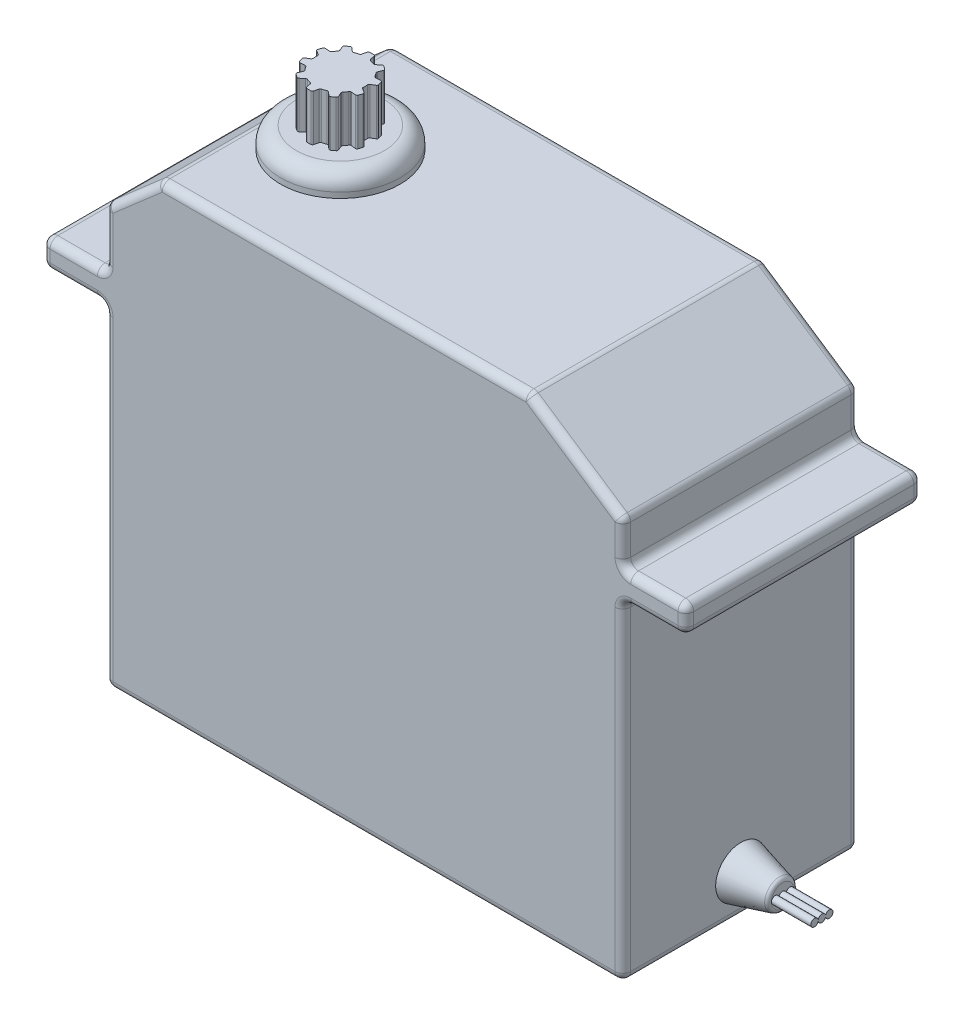
from build123d import *

# Parameters (mm, degrees)
BOSS_EXTRU_1_DEPTH         = 15
BOSS_EXTRU_1_DEPTH_BACK    = 15
ESQUISSE4_R                = 5
ESQUISSE4_R_2              = 4
ENL_V_MAT_EXTRU_1_DEPTH    = 5.9
CONG_2_R                   = 1
CONG_3_R                   = 2
CONG_4_R                   = 0.5
ESQUISSE6_W                = 7.5
ESQUISSE6_H                = 0.471666667
R_P_TITION_LIN_AIRE1_COUNT = 3
R_P_TITION_LIN_AIRE1_PITCH = 0.94


with BuildPart() as part:
    # Esquisse1 → Boss.-Extru.1 (new body, two sides)
    with BuildSketch(Plane.XY) as boss_extru_1_sk:
        Polygon((32.9, -29.5), (-32.9, -29.5), (-32.9, 12.6), (-40.9, 12.6), (-40.9, 16.1), (-32.9, 16.1), (-32.9, 23.5), (-26.017303953, 29.5), (20.9, 29.5), (32.9, 21.5), (32.9, 16.1), (40.9, 16.1), (40.9, 12.6), (32.9, 12.6), align=None)
    extrude(amount=BOSS_EXTRU_1_DEPTH)
    extrude(boss_extru_1_sk.sketch, amount=-BOSS_EXTRU_1_DEPTH_BACK)

    # Esquisse3 → R_volution1 (revolve)
    with BuildSketch(Plane.XY):
        Polygon((-18, 38.1), (-22, 38.1), (-22, 32.2), (-25.6, 32.2), (-25.6, 29.5), (-18, 29.5), align=None)
    revolve(axis=Axis((-18, 29.5, 0), (0, 1, 0)))

    # Esquisse4 → Enl_v. mat.-Extru.1 (cut)
    with BuildSketch(Plane(origin=(0, 38.1, 0), x_dir=(1, 0, 0), z_dir=(0, 1, 0))):
        with Locations((-18, 0)):
            Circle(ESQUISSE4_R)
        with Locations((-18, 0)):
            Circle(ESQUISSE4_R_2, mode=Mode.SUBTRACT)
        with BuildLine():
            ThreePointArc((-21.517415729, -1.598517271), (-21.638903745, -1.568819647), (-21.71899927, -1.472767609))
            ThreePointArc((-21.71899927, -1.472767609), (-21.236067977, -2.351141009), (-20.549919208, -3.08186827))
            ThreePointArc((-20.549919208, -3.08186827), (-20.616519246, -2.976011187), (-20.607221503, -2.851292147))
            Line((-20.607221503, -2.851292147), (-20.381739148, -2.306479516))
            ThreePointArc((-20.381739148, -2.306479516), (-20.369139043, -2.197842689), (-20.415564615, -2.098820524))
            ThreePointArc((-20.415564615, -2.098820524), (-20.588854382, -1.880912807), (-20.742547453, -1.648767257))
            ThreePointArc((-20.742547453, -1.648767257), (-20.822376837, -1.574014383), (-20.929590246, -1.552427169))
            Line((-20.929590246, -1.552427169), (-21.517415729, -1.598517271))
        make_face()
        with BuildLine():
            ThreePointArc((-21.785233978, 0.774257454), (-21.866064022, 0.869692201), (-21.874404692, 0.994478899))
            ThreePointArc((-21.874404692, 0.994478899), (-22, 0), (-21.874404692, -0.994478899))
            ThreePointArc((-21.874404692, -0.994478899), (-21.866064022, -0.869692201), (-21.785233978, -0.774257454))
            Line((-21.785233978, -0.774257454), (-21.282582091, -0.46602998))
            ThreePointArc((-21.282582091, -0.46602998), (-21.208533267, -0.385547096), (-21.187888576, -0.278148216))
            ThreePointArc((-21.187888576, -0.278148216), (-21.2, 0), (-21.187888576, 0.278148216))
            ThreePointArc((-21.187888576, 0.278148216), (-21.208533267, 0.385547096), (-21.282582091, 0.46602998))
            Line((-21.282582091, 0.46602998), (-21.785233978, 0.774257454))
        make_face()
        with BuildLine():
            ThreePointArc((-20.607221503, 2.851292147), (-20.616519246, 2.976011187), (-20.549919208, 3.08186827))
            ThreePointArc((-20.549919208, 3.08186827), (-21.236067977, 2.351141009), (-21.71899927, 1.472767609))
            ThreePointArc((-21.71899927, 1.472767609), (-21.638903745, 1.568819647), (-21.517415729, 1.598517271))
            Line((-21.517415729, 1.598517271), (-20.929590246, 1.552427169))
            ThreePointArc((-20.929590246, 1.552427169), (-20.822376837, 1.574014383), (-20.742547453, 1.648767257))
            ThreePointArc((-20.742547453, 1.648767257), (-20.588854382, 1.880912807), (-20.415564615, 2.098820524))
            ThreePointArc((-20.415564615, 2.098820524), (-20.369139043, 2.197842689), (-20.381739148, 2.306479516))
            Line((-20.381739148, 2.306479516), (-20.607221503, 2.851292147))
        make_face()
        with BuildLine():
            Line((-18.571152803, 3.265932271), (-18.43333903, 3.839230152))
            ThreePointArc((-18.43333903, 3.839230152), (-18.36755305, 3.945595051), (-18.251451255, 3.99208871))
            ThreePointArc((-18.251451255, 3.99208871), (-19.236067977, 3.804226065), (-20.14306253, 3.377466949))
            ThreePointArc((-20.14306253, 3.377466949), (-20.021805919, 3.408095711), (-19.906064224, 3.36071273))
            Line((-19.906064224, 3.36071273), (-19.4575945, 2.977909904))
            ThreePointArc((-19.4575945, 2.977909904), (-19.358168385, 2.932355866), (-19.249646419, 2.945909677))
            ThreePointArc((-19.249646419, 2.945909677), (-18.988854382, 3.043380852), (-18.720577073, 3.117814729))
            ThreePointArc((-18.720577073, 3.117814729), (-18.624814228, 3.170637076), (-18.571152803, 3.265932271))
        make_face()
        with BuildLine():
            ThreePointArc((-15.85693747, 3.377466949), (-16.763932023, 3.804226065), (-17.748548745, 3.99208871))
            ThreePointArc((-17.748548745, 3.99208871), (-17.63244695, 3.945595051), (-17.56666097, 3.839230152))
            Line((-17.56666097, 3.839230152), (-17.428847197, 3.265932271))
            ThreePointArc((-17.428847197, 3.265932271), (-17.375185772, 3.170637076), (-17.279422927, 3.117814729))
            ThreePointArc((-17.279422927, 3.117814729), (-17.011145618, 3.043380852), (-16.750353581, 2.945909677))
            ThreePointArc((-16.750353581, 2.945909677), (-16.641831615, 2.932355866), (-16.5424055, 2.977909904))
            Line((-16.5424055, 2.977909904), (-16.093935776, 3.36071273))
            ThreePointArc((-16.093935776, 3.36071273), (-15.978194081, 3.408095711), (-15.85693747, 3.377466949))
        make_face()
        with BuildLine():
            ThreePointArc((-14.28100073, 1.472767609), (-14.763932023, 2.351141009), (-15.450080792, 3.08186827))
            ThreePointArc((-15.450080792, 3.08186827), (-15.383480754, 2.976011187), (-15.392778497, 2.851292147))
            Line((-15.392778497, 2.851292147), (-15.618260852, 2.306479516))
            ThreePointArc((-15.618260852, 2.306479516), (-15.630860957, 2.197842689), (-15.584435385, 2.098820524))
            ThreePointArc((-15.584435385, 2.098820524), (-15.411145618, 1.880912807), (-15.257452547, 1.648767257))
            ThreePointArc((-15.257452547, 1.648767257), (-15.177623163, 1.574014383), (-15.070409754, 1.552427169))
            Line((-15.070409754, 1.552427169), (-14.482584271, 1.598517271))
            ThreePointArc((-14.482584271, 1.598517271), (-14.361096255, 1.568819647), (-14.28100073, 1.472767609))
        make_face()
        with BuildLine():
            ThreePointArc((-14, 0), (-14.03152304, 0.501189201), (-14.125595308, 0.994478899))
            ThreePointArc((-14.125595308, 0.994478899), (-14.133935978, 0.869692201), (-14.214766022, 0.774257454))
            Line((-14.214766022, 0.774257454), (-14.717417909, 0.46602998))
            ThreePointArc((-14.717417909, 0.46602998), (-14.791466733, 0.385547096), (-14.812111424, 0.278148216))
            ThreePointArc((-14.812111424, 0.278148216), (-14.8, 0), (-14.812111424, -0.278148216))
            ThreePointArc((-14.812111424, -0.278148216), (-14.791466733, -0.385547096), (-14.717417909, -0.46602998))
            Line((-14.717417909, -0.46602998), (-14.214766022, -0.774257454))
            ThreePointArc((-14.214766022, -0.774257454), (-14.133935978, -0.869692201), (-14.125595308, -0.994478899))
            ThreePointArc((-14.125595308, -0.994478899), (-14.03152304, -0.501189201), (-14, 0))
        make_face()
        with BuildLine():
            ThreePointArc((-15.450080792, -3.08186827), (-14.763932023, -2.351141009), (-14.28100073, -1.472767609))
            ThreePointArc((-14.28100073, -1.472767609), (-14.361096255, -1.568819647), (-14.482584271, -1.598517271))
            Line((-14.482584271, -1.598517271), (-15.070409754, -1.552427169))
            ThreePointArc((-15.070409754, -1.552427169), (-15.177623163, -1.574014383), (-15.257452547, -1.648767257))
            ThreePointArc((-15.257452547, -1.648767257), (-15.411145618, -1.880912807), (-15.584435385, -2.098820524))
            ThreePointArc((-15.584435385, -2.098820524), (-15.630860957, -2.197842689), (-15.618260852, -2.306479516))
            Line((-15.618260852, -2.306479516), (-15.392778497, -2.851292147))
            ThreePointArc((-15.392778497, -2.851292147), (-15.383480754, -2.976011187), (-15.450080792, -3.08186827))
        make_face()
        with BuildLine():
            ThreePointArc((-17.748548745, -3.99208871), (-16.763932023, -3.804226065), (-15.85693747, -3.377466949))
            ThreePointArc((-15.85693747, -3.377466949), (-15.978194081, -3.408095711), (-16.093935776, -3.36071273))
            Line((-16.093935776, -3.36071273), (-16.5424055, -2.977909904))
            ThreePointArc((-16.5424055, -2.977909904), (-16.641831615, -2.932355866), (-16.750353581, -2.945909677))
            ThreePointArc((-16.750353581, -2.945909677), (-17.011145618, -3.043380852), (-17.279422927, -3.117814729))
            ThreePointArc((-17.279422927, -3.117814729), (-17.375185772, -3.170637076), (-17.428847197, -3.265932271))
            Line((-17.428847197, -3.265932271), (-17.56666097, -3.839230152))
            ThreePointArc((-17.56666097, -3.839230152), (-17.63244695, -3.945595051), (-17.748548745, -3.99208871))
        make_face()
        with BuildLine():
            ThreePointArc((-19.906064224, -3.36071273), (-20.021805919, -3.408095711), (-20.14306253, -3.377466949))
            ThreePointArc((-20.14306253, -3.377466949), (-19.236067977, -3.804226065), (-18.251451255, -3.99208871))
            ThreePointArc((-18.251451255, -3.99208871), (-18.36755305, -3.945595051), (-18.43333903, -3.839230152))
            Line((-18.43333903, -3.839230152), (-18.571152803, -3.265932271))
            ThreePointArc((-18.571152803, -3.265932271), (-18.624814228, -3.170637076), (-18.720577073, -3.117814729))
            ThreePointArc((-18.720577073, -3.117814729), (-18.988854382, -3.043380852), (-19.249646419, -2.945909677))
            ThreePointArc((-19.249646419, -2.945909677), (-19.358168385, -2.932355866), (-19.4575945, -2.977909904))
            Line((-19.4575945, -2.977909904), (-19.906064224, -3.36071273))
        make_face()
    extrude(amount=-ENL_V_MAT_EXTRU_1_DEPTH, mode=Mode.SUBTRACT)

    # Cong_2
    cong_2_edges = [part.edges().sort_by_distance(p)[0] for p in [
        (40.9, 14.35, -15),
        (36.9, 16.1, -15),
        (32.9, 18.8, -15),
        (32.9, -29.5, 0),
        (-32.9, -29.5, 0),
        (-32.9, 12.6, 0),
        (-40.9, 12.6, 0),
        (-40.9, 16.1, 0),
        (-32.9, 16.1, 0),
        (-32.9, 23.5, 0),
        (-26.017303953, 29.5, 0),
        (20.9, 29.5, 0),
        (32.9, 21.5, 0),
        (32.9, 16.1, 0),
        (26.9, 25.5, -15),
        (40.9, 16.1, 0),
        (40.9, 12.6, 0),
        (32.9, 12.6, 0),
        (-2.558651977, 29.5, -15),
        (-29.458651977, 26.5, -15),
        (-32.9, 19.8, -15),
        (32.9, -8.45, 15),
        (36.9, 12.6, 15),
        (40.9, 14.35, 15),
        (36.9, 16.1, 15),
        (-36.9, 16.1, -15),
        (32.9, 18.8, 15),
        (26.9, 25.5, 15),
        (-2.558651977, 29.5, 15),
        (-29.458651977, 26.5, 15),
        (-32.9, 19.8, 15),
        (-36.9, 16.1, 15),
        (-40.9, 14.35, 15),
        (-36.9, 12.6, 15),
        (-32.9, -8.45, 15),
        (0, -29.5, 15),
        (-40.9, 14.35, -15),
        (-36.9, 12.6, -15),
        (32.9, -8.45, -15),
        (-32.9, -8.45, -15),
        (0, -29.5, -15),
        (36.9, 12.6, -15),
    ]]
    fillet(cong_2_edges, radius=CONG_2_R)

    # Cong_3
    cong_3_edges = [part.edges().sort_by_distance(p)[0] for p in [
        (-10.4, 32.2, 0),
    ]]
    fillet(cong_3_edges, radius=CONG_3_R)

    # Esquisse5 → R_volution2 (revolve)
    with BuildSketch(Plane.XY):
        Polygon((38.2, -24.5), (38.2, -26.3), (32.9, -27.7), (32.9, -24.5), align=None)
    revolve(axis=Axis((32.9, -24.5, 0), (1, 0, 0)))

    # Cong_4
    cong_4_edges = [part.edges().sort_by_distance(p)[0] for p in [
        (38.2, -22.7, 0),
    ]]
    fillet(cong_4_edges, radius=CONG_4_R)

    # Esquisse6 → R_volution3 (revolve)
    with BuildSketch(Plane(origin=(0, -24.5, 0), x_dir=(1, 0, 0), z_dir=(0, 1, 0))):
        with Locations((39.45, -1.179092325)):
            Rectangle(ESQUISSE6_W, ESQUISSE6_H)
    r_volution3 = revolve(axis=Axis((43.2, -24.5, 0.943258991), (-1, 0, 0)))

    # R_p_tition lin_aire1: R_volution3 ×3
    with Locations(*[(0, 0, -i * R_P_TITION_LIN_AIRE1_PITCH) for i in range(1, R_P_TITION_LIN_AIRE1_COUNT)]):
        add(r_volution3)


solid = part.part
